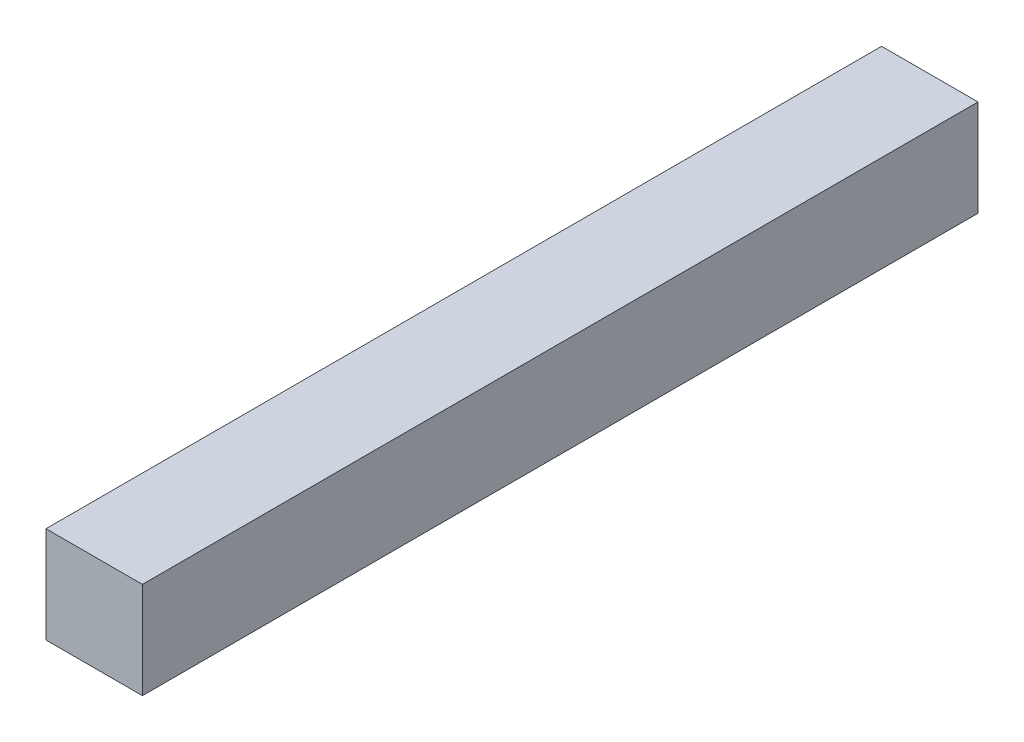
from build123d import *

# Parameters (mm, degrees)
SKETCH1_W           = 1.5
SKETCH1_H           = 1.5
BOSS_EXTRUDE1_DEPTH = 13


with BuildPart() as part:
    # Sketch1 → Boss-Extrude1 (new body)
    with BuildSketch(Plane.XY):
        Rectangle(SKETCH1_W, SKETCH1_H)
    extrude(amount=BOSS_EXTRUDE1_DEPTH)


solid = part.part
